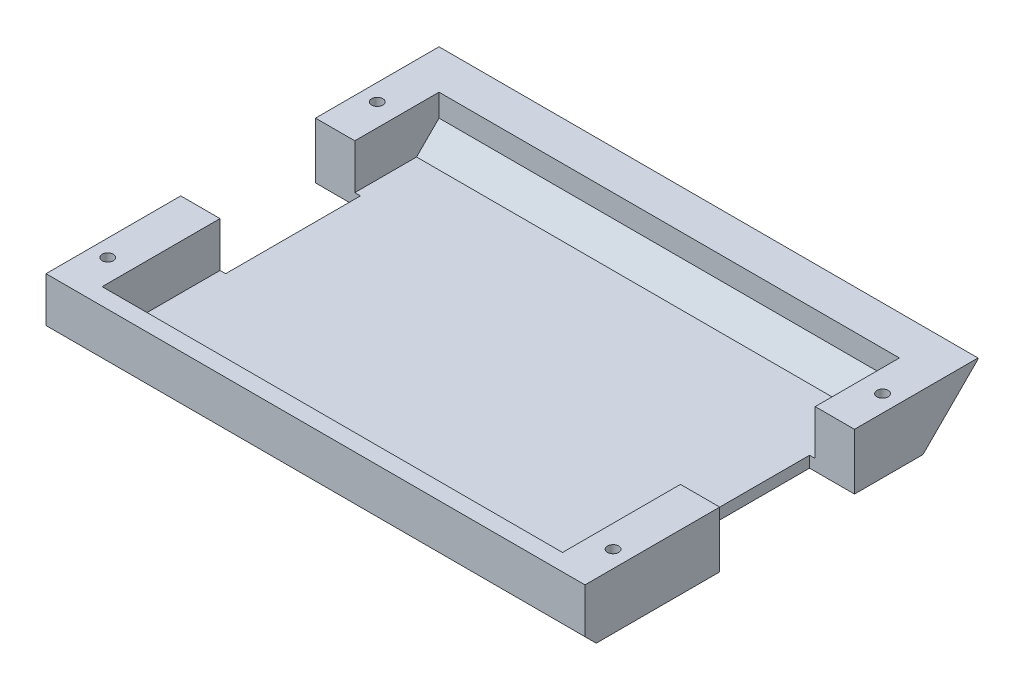
from build123d import *

# Parameters (mm, degrees)
SKETCH_1_W          = 48
SKETCH_1_H          = 35
EXTRUDE_1_DEPTH     = 5
SKETCH_2_W          = 41
SKETCH_2_H          = 30
CUT_EXTRUDE_1_DEPTH = 4
SKETCH_3_R          = 0.5
CUT_EXTRUDE_2_DEPTH = 6
SKETCH_4_R          = 1
CUT_EXTRUDE_5_DEPTH = 4
SKETCH_5_W          = 4
SKETCH_5_H          = 12
CUT_EXTRUDE_4_DEPTH = 6
CHAMFER_2_SIZE      = 4.9
CHAMFER_3_SIZE      = 1
CHAMFER_6_SIZE      = 2


with BuildPart() as part:
    # 草图1 → 凸台-拉伸1 (new body)
    with BuildSketch(Plane(origin=(0, 0, 0), x_dir=(1, 0, 0), z_dir=(0, 1, 0))):
        Rectangle(SKETCH_1_W, SKETCH_1_H)
    extrude(amount=EXTRUDE_1_DEPTH)

    # 草图2 → 切除-拉伸1 (cut)
    with BuildSketch(Plane(origin=(0, 5, 0), x_dir=(1, 0, 0), z_dir=(0, 1, 0))):
        with Locations((0, -1)):
            Rectangle(SKETCH_2_W, SKETCH_2_H)
    extrude(amount=-CUT_EXTRUDE_1_DEPTH, mode=Mode.SUBTRACT)

    # 草图3 → 切除-拉伸2 (cut, through all)
    with BuildSketch(Plane(origin=(0, 5, 0), x_dir=(1, 0, 0), z_dir=(0, 1, 0))):
        with Locations((-22.5, 10.5)):
            Circle(SKETCH_3_R)
        with Locations((-22.5, -13.5)):
            Circle(SKETCH_3_R)
        with Locations((22.5, -13.5)):
            Circle(SKETCH_3_R)
        with Locations((22.5, 10.5)):
            Circle(SKETCH_3_R)
    extrude(amount=-CUT_EXTRUDE_2_DEPTH, mode=Mode.SUBTRACT)

    # 草图4 → 切除-拉伸5 (cut)
    with BuildSketch(Plane.XZ):
        with Locations((-22.5, -10.5)):
            Circle(SKETCH_4_R)
        with Locations((-22.5, 13.5)):
            Circle(SKETCH_4_R)
        with Locations((22.5, 13.5)):
            Circle(SKETCH_4_R)
        with Locations((22.5, -10.5)):
            Circle(SKETCH_4_R)
    extrude(amount=-CUT_EXTRUDE_5_DEPTH, mode=Mode.SUBTRACT)

    # 草图5 → 切除-拉伸4 (cut, through all)
    with BuildSketch(Plane(origin=(0, 5, 0), x_dir=(1, 0, 0), z_dir=(0, 1, 0))):
        with Locations((-22, 0.5)):
            Rectangle(SKETCH_5_W, SKETCH_5_H)
        with Locations((22, 0.5)):
            Rectangle(SKETCH_5_W, SKETCH_5_H)
    extrude(amount=-CUT_EXTRUDE_4_DEPTH, mode=Mode.SUBTRACT)

    # 倒角2
    chamfer_2_edges = [part.edges().sort_by_distance(p)[0] for p in [
        (0, 0, -17.5),
    ]]
    chamfer(chamfer_2_edges, length=CHAMFER_2_SIZE)

    # 倒角3
    chamfer_3_edges = [part.edges().sort_by_distance(p)[0] for p in [
        (0, 0, 17.5),
    ]]
    chamfer(chamfer_3_edges, length=CHAMFER_3_SIZE)

    # 倒角6
    chamfer_6_edges = [part.edges().sort_by_distance(p)[0] for p in [
        (0, 1, -14),
    ]]
    chamfer(chamfer_6_edges, length=CHAMFER_6_SIZE)


solid = part.part
